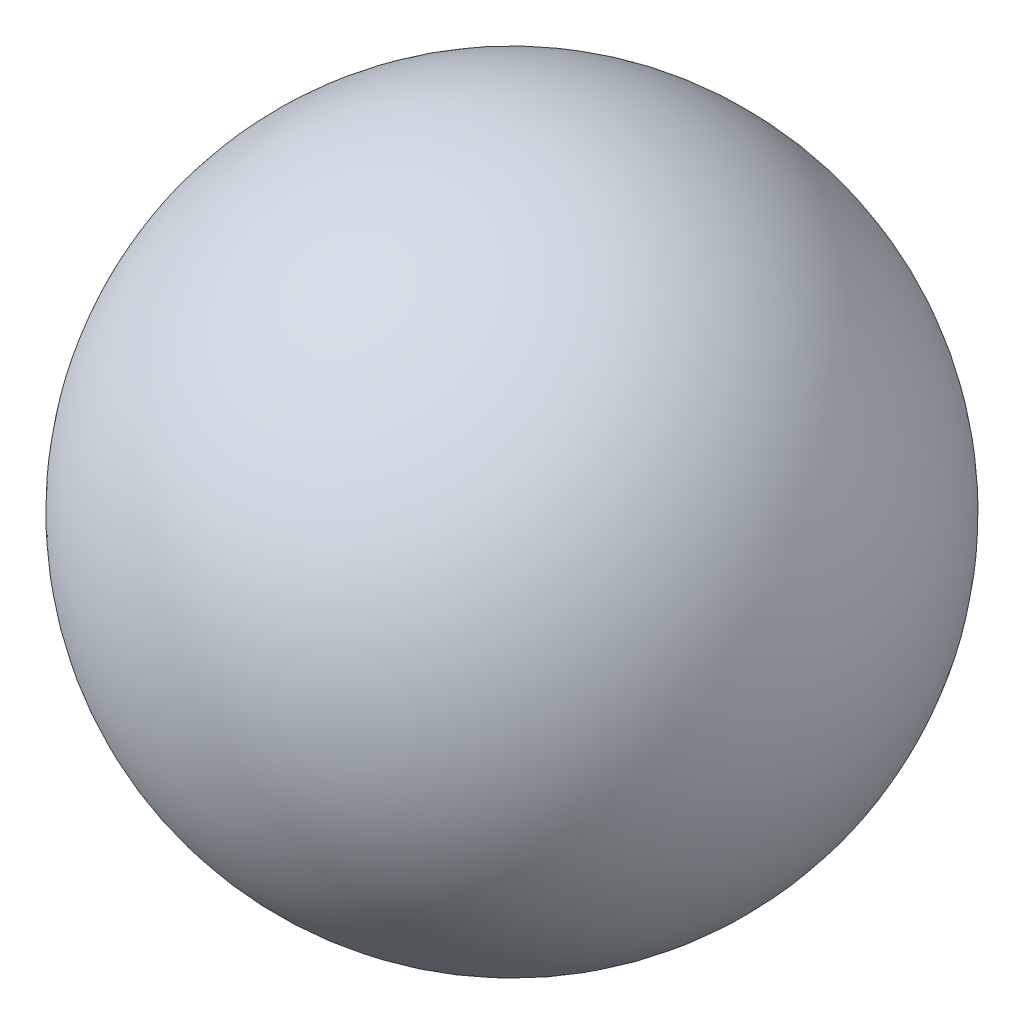
from build123d import *


with BuildPart() as part:
    # Sketch1 → Revolve4 (revolve)
    with BuildSketch(Plane.XY):
        with BuildLine():
            Line((-75, 0), (75, 0))
            ThreePointArc((75, 0), (0, 75), (-75, 0))
        make_face()
    revolve(axis=Axis((-75, 0, 0), (1, 0, 0)))


solid = part.part
